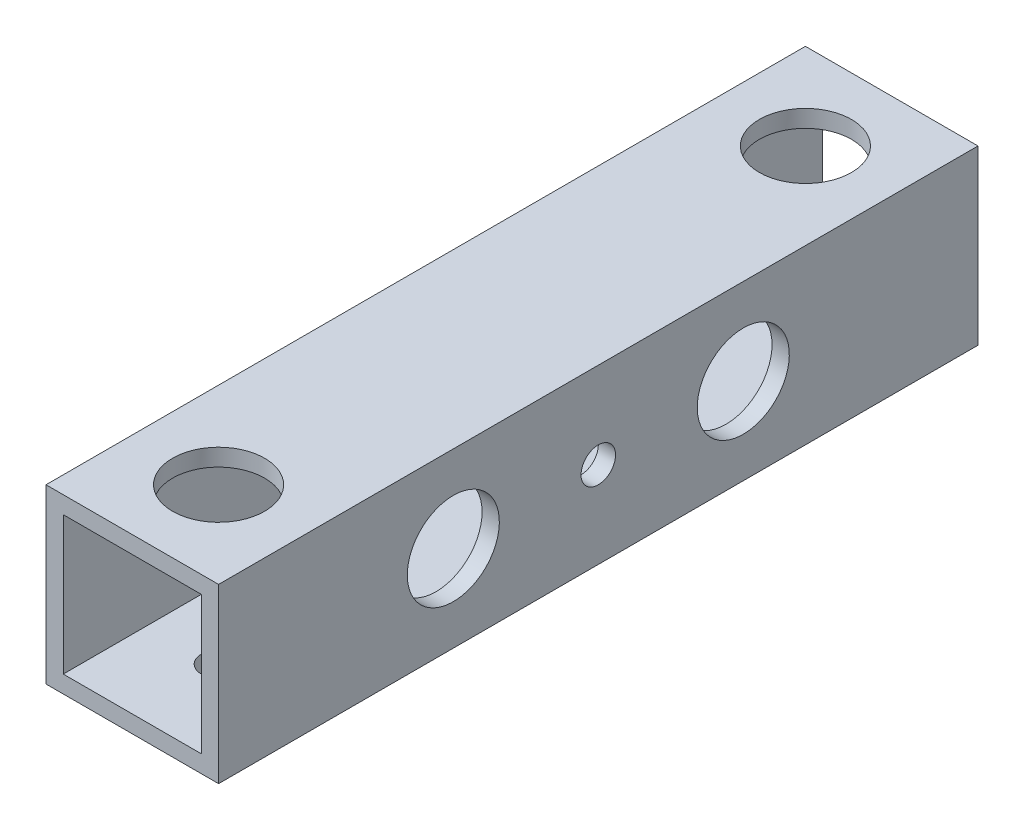
from build123d import *

# Parameters (mm, degrees)
SKETCH_1_W          = 15
SKETCH_1_H          = 15
SKETCH_1_W_2        = 12
SKETCH_1_H_2        = 12
EXTRUDE_2_DEPTH     = 66
SKETCH_3_R          = 4
CUT_EXTRUDE_1_DEPTH = 10
SKETCH_4_R          = 4
CUT_EXTRUDE_2_DEPTH = 10
SKETCH_5_R          = 4
CUT_EXTRUDE_3_DEPTH = 10
SKETCH_6_R          = 1.5
CUT_EXTRUDE_4_DEPTH = 10
SKETCH_7_R          = 1.5
CUT_EXTRUDE_5_DEPTH = 10
SKETCH_8_R          = 1.5
CUT_EXTRUDE_6_DEPTH = 10
SKETCH_9_R          = 4
CUT_EXTRUDE_7_DEPTH = 10


with BuildPart() as part:
    # ｽｹｯﾁ1 → ﾎﾞｽ - 押し出し2 (new body)
    with BuildSketch(Plane.XY):
        with Locations((0.489915859, 0.232626086)):
            Rectangle(SKETCH_1_W, SKETCH_1_H)
        with Locations((0.489915859, 0.232626086)):
            Rectangle(SKETCH_1_W_2, SKETCH_1_H_2, mode=Mode.SUBTRACT)
    extrude(amount=EXTRUDE_2_DEPTH)

    # ｽｹｯﾁ3 → ｶｯﾄ - 押し出し1 (cut)
    with BuildSketch(Plane(origin=(0, 7.732626086, 0), x_dir=(1, 0, 0), z_dir=(0, 1, 0))):
        with Locations((0.489915859, -58.5)):
            Circle(SKETCH_3_R)
    extrude(amount=-CUT_EXTRUDE_1_DEPTH, mode=Mode.SUBTRACT)

    # ｽｹｯﾁ4 → ｶｯﾄ - 押し出し2 (cut)
    with BuildSketch(Plane(origin=(0, 7.732626086, 0), x_dir=(1, 0, 0), z_dir=(0, 1, 0))):
        with Locations((0.489915859, -7.5)):
            Circle(SKETCH_4_R)
    extrude(amount=-CUT_EXTRUDE_2_DEPTH, mode=Mode.SUBTRACT)

    # ｽｹｯﾁ5 → ｶｯﾄ - 押し出し3 (cut)
    with BuildSketch(Plane.ZY.offset(7.010084141)):
        with Locations((33, 0.232626086)):
            Circle(SKETCH_5_R)
    extrude(amount=-CUT_EXTRUDE_3_DEPTH, mode=Mode.SUBTRACT)

    # ｽｹｯﾁ6 → ｶｯﾄ - 押し出し4 (cut)
    with BuildSketch(Plane(origin=(7.989915859, 0, 0), x_dir=(0, 0, -1), z_dir=(1, 0, 0))):
        with Locations((-33, 0.232626086)):
            Circle(SKETCH_6_R)
    extrude(amount=-CUT_EXTRUDE_4_DEPTH, mode=Mode.SUBTRACT)

    # ｽｹｯﾁ7 → ｶｯﾄ - 押し出し5 (cut)
    with BuildSketch(Plane.XZ.offset(7.267373914)):
        with Locations((0.489915859, 58.5)):
            Circle(SKETCH_7_R)
        with Locations((0.489915859, 7.5)):
            Circle(SKETCH_7_R)
    extrude(amount=-CUT_EXTRUDE_5_DEPTH, mode=Mode.SUBTRACT)

    # ｽｹｯﾁ8 → ｶｯﾄ - 押し出し6 (cut)
    with BuildSketch(Plane.ZY.offset(7.010084141)):
        with Locations((45.6, 0.232626086)):
            Circle(SKETCH_8_R)
        with Locations((20.4, 0.232626086)):
            Circle(SKETCH_8_R)
    extrude(amount=-CUT_EXTRUDE_6_DEPTH, mode=Mode.SUBTRACT)

    # ｽｹｯﾁ9 → ｶｯﾄ - 押し出し7 (cut)
    with BuildSketch(Plane(origin=(7.989915859, 0, 0), x_dir=(0, 0, -1), z_dir=(1, 0, 0))):
        with Locations((-20.4, 0.232626086)):
            Circle(SKETCH_9_R)
        with Locations((-45.6, 0.232626086)):
            Circle(SKETCH_9_R)
    extrude(amount=-CUT_EXTRUDE_7_DEPTH, mode=Mode.SUBTRACT)


solid = part.part
